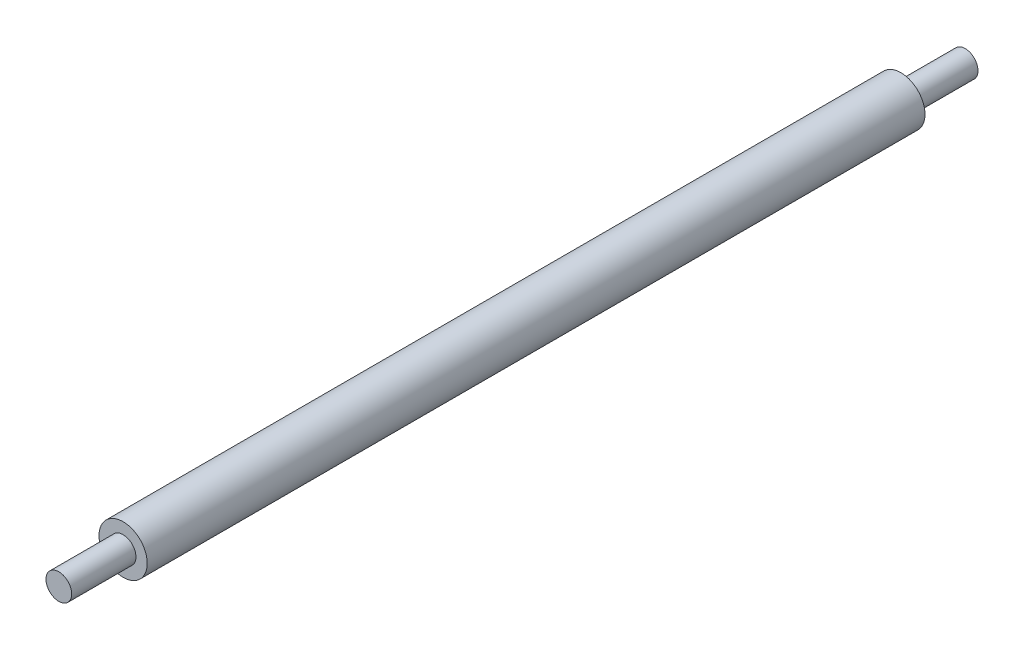
from build123d import *

# Parameters (mm, degrees)
SKETCH1_R           = 7.5
BOSS_EXTRUDE1_DEPTH = 242
SKETCH2_R           = 4
BOSS_EXTRUDE2_DEPTH = 20


with BuildPart() as part:
    # Sketch1 → Boss-Extrude1 (new body)
    with BuildSketch(Plane.XY):
        Circle(SKETCH1_R)
    extrude(amount=BOSS_EXTRUDE1_DEPTH)

    # Sketch2 → Boss-Extrude2 (add)
    with BuildSketch(Plane.XY.offset(242)):
        Circle(SKETCH2_R)
    boss_extrude2 = extrude(amount=BOSS_EXTRUDE2_DEPTH)

    # Mirror1: Boss-Extrude2 across plane
    add(boss_extrude2.mirror(Plane.XY.offset(121)))


solid = part.part
